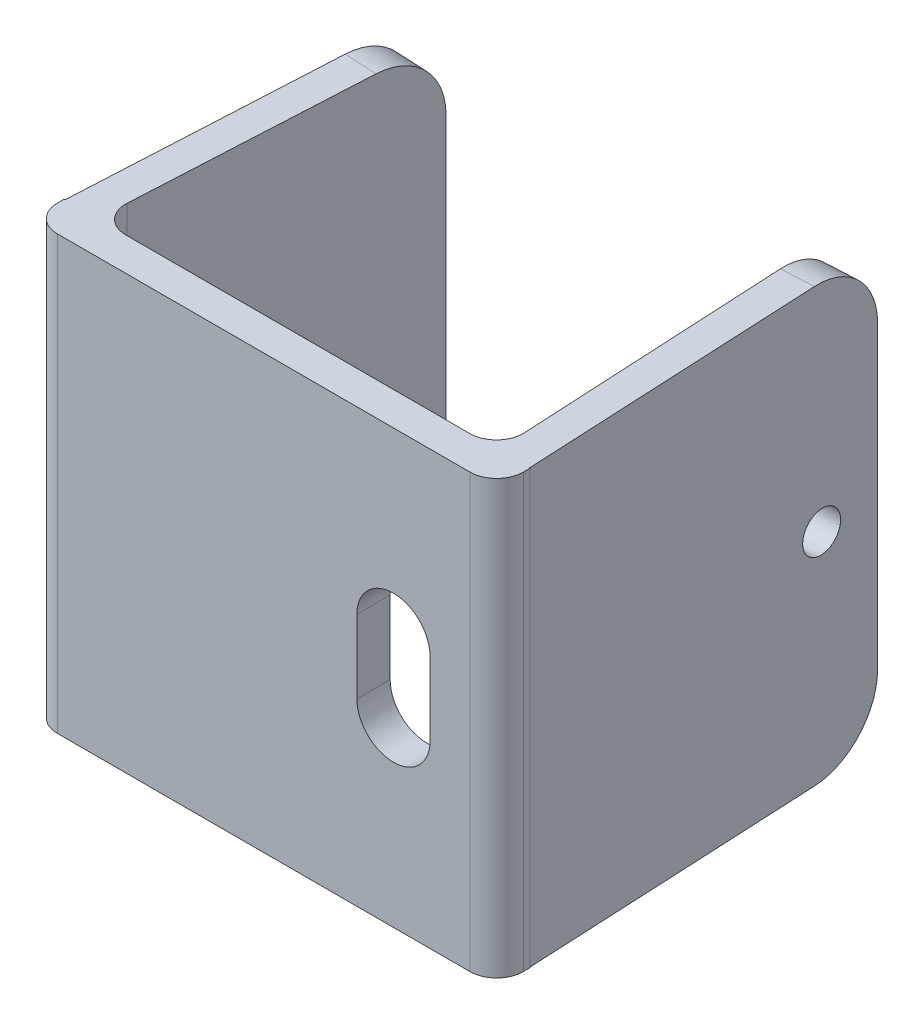
from build123d import *

# Parameters (mm, degrees)
SKETCH_1_W          = 35
SKETCH_1_H          = 32.5
EXTRUDE_1_DEPTH     = 2.5
EXTRUDE_2_DEPTH     = 32.5
FILLET_1_R          = 2
FILLET_2_R          = 5
SKETCH_3_R          = 1.5
CUT_EXTRUDE_1_DEPTH = 10
CUT_EXTRUDE_2_DEPTH = 10


with BuildPart() as part:
    # 草图1 → 凸台-拉伸1 (new body)
    with BuildSketch(Plane.XY):
        Rectangle(SKETCH_1_W, SKETCH_1_H)
    extrude(amount=EXTRUDE_1_DEPTH)

    # 草图2 → 凸台-拉伸2 (add)
    with BuildSketch(Plane.XZ.offset(16.25)):
        Polygon((-13.675929559, -24.871935947), (-14.98280876, 0.054942395), (-17.43216424, 0.054942395), (-16.118570831, -25), align=None)
        Polygon((16.118570831, -27.5), (13.675929559, -27.371935947), (15.108562872, 0.305766553), (17.5, 0.82312635), align=None)
    extrude(amount=-EXTRUDE_2_DEPTH)

    # 圆角1
    fillet_1_edges = [part.edges().sort_by_distance(p)[0] for p in [
        (17.5, 0, 2.5),
        (-14.979928212, 0, 0),
        (15.092736004, 0, 0),
        (-17.5, 0, 2.5),
    ]]
    fillet(fillet_1_edges, radius=FILLET_1_R)

    # 圆角2
    fillet_2_edges = [part.edges().sort_by_distance(p)[0] for p in [
        (-14.897250195, -16.25, -24.935967973),
        (-14.897250195, 16.25, -24.935967973),
        (14.897250195, -16.25, -27.435967973),
        (14.897250195, 16.25, -27.435967973),
    ]]
    fillet(fillet_2_edges, radius=FILLET_2_R)

    # 草图3 → 切除-拉伸1 (cut)
    with BuildSketch(Plane(origin=(17.418416378, 0, -0.849563998), x_dir=(-0.048715984, 0, -0.998812672), z_dir=(0.998812672, 0, -0.048715984))):
        with Locations((22.256634944, 0)):
            Circle(SKETCH_3_R)
    extrude(amount=-CUT_EXTRUDE_1_DEPTH, mode=Mode.SUBTRACT)

    # 草图4 → 切除-拉伸2 (cut)
    with BuildSketch(Plane.XY.offset(2.5)):
        with BuildLine():
            Line((12.5, 2.75), (12.5, -2.75))
            ThreePointArc((12.5, -2.75), (9.75, -5.5), (7, -2.75))
            Line((7, -2.75), (7, 2.75))
            ThreePointArc((7, 2.75), (9.75, 5.5), (12.5, 2.75))
        make_face()
    extrude(amount=-CUT_EXTRUDE_2_DEPTH, mode=Mode.SUBTRACT)


solid = part.part
